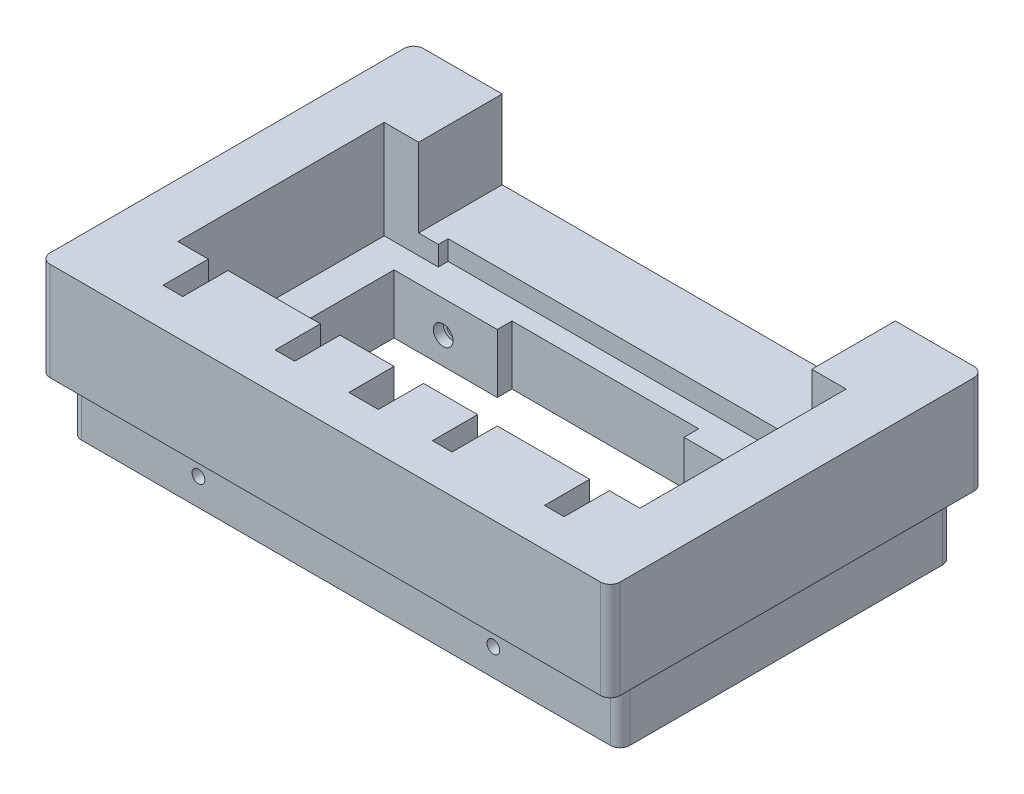
from build123d import *

# Parameters (mm, degrees)
SKETCH1_W               = 279
SKETCH1_H               = 169
BOSS_EXTRUDE1_DEPTH     = 30
SKETCH2_W               = 290
SKETCH2_H               = 190
BOSS_EXTRUDE2_DEPTH     = 50
FILLET1_R               = 5
FILLET2_R               = 5
SKETCH3_W               = 235
SKETCH3_H               = 105
CUT_EXTRUDE1_DEPTH      = 50
SKETCH4_W               = 200
SKETCH4_H               = 80
CUT_EXTRUDE2_DEPTH      = 50
SKETCH5_W               = 180
SKETCH5_H               = 5
CUT_EXTRUDE3_DEPTH      = 50
SKETCH6_W               = 95
SKETCH6_H               = 95
CUT_EXTRUDE4_DEPTH      = 50
SKETCH7_W               = 15
SKETCH7_H               = 23
SKETCH7_W_2             = 10
CUT_EXTRUDE5_DEPTH      = 50
SKETCH8_R               = 3.25
CUT_EXTRUDE6_DEPTH      = 180.5
SKETCH9_R               = 5
CUT_EXTRUDE7_DEPTH      = 45
CUT_EXTRUDE7_DEPTH_BACK = 45
SKETCH11_W              = 200
SKETCH11_H              = 40
CUT_EXTRUDE9_DEPTH      = 50


with BuildPart() as part:
    # Sketch1 → Boss-Extrude1 (new body)
    with BuildSketch(Plane(origin=(0, 0, 0), x_dir=(1, 0, 0), z_dir=(0, 1, 0))):
        Rectangle(SKETCH1_W, SKETCH1_H)
    extrude(amount=-BOSS_EXTRUDE1_DEPTH)

    # Sketch2 → Boss-Extrude2 (add)
    with BuildSketch(Plane(origin=(0, 0, 0), x_dir=(1, 0, 0), z_dir=(0, 1, 0))):
        Rectangle(SKETCH2_W, SKETCH2_H)
    extrude(amount=BOSS_EXTRUDE2_DEPTH)

    # Fillet1
    fillet1_edges = [part.edges().sort_by_distance(p)[0] for p in [
        (139.5, -15, 84.5),
        (-139.5, -15, 84.5),
        (-139.5, -15, -84.5),
        (139.5, -15, -84.5),
    ]]
    fillet(fillet1_edges, radius=FILLET1_R)

    # Fillet2
    fillet2_edges = [part.edges().sort_by_distance(p)[0] for p in [
        (145, 25, 95),
        (145, 25, -95),
        (-145, 25, -95),
        (-145, 25, 95),
    ]]
    fillet(fillet2_edges, radius=FILLET2_R)

    # Sketch3 → Cut-Extrude1 (cut)
    with BuildSketch(Plane(origin=(0, 50, 0), x_dir=(1, 0, 0), z_dir=(0, 1, 0))):
        Rectangle(SKETCH3_W, SKETCH3_H)
    extrude(amount=-CUT_EXTRUDE1_DEPTH, mode=Mode.SUBTRACT)

    # Sketch4 → Cut-Extrude2 (cut)
    with BuildSketch(Plane(origin=(0, 0, 0), x_dir=(1, 0, 0), z_dir=(0, 1, 0))):
        Rectangle(SKETCH4_W, SKETCH4_H)
    extrude(amount=-CUT_EXTRUDE2_DEPTH, mode=Mode.SUBTRACT)

    # Sketch5 → Cut-Extrude3 (cut)
    with BuildSketch(Plane(origin=(0, 50, 0), x_dir=(1, 0, 0), z_dir=(0, 1, 0))):
        with Locations((0, 55)):
            Rectangle(SKETCH5_W, SKETCH5_H)
    extrude(amount=-CUT_EXTRUDE3_DEPTH, mode=Mode.SUBTRACT)

    # Sketch6 → Cut-Extrude4 (cut)
    with BuildSketch(Plane(origin=(0, 0, 0), x_dir=(1, 0, 0), z_dir=(0, 1, 0))):
        Rectangle(SKETCH6_W, SKETCH6_H)
    extrude(amount=-CUT_EXTRUDE4_DEPTH, mode=Mode.SUBTRACT)

    # Sketch7 → Cut-Extrude5 (cut)
    with BuildSketch(Plane(origin=(0, 50, 0), x_dir=(1, 0, 0), z_dir=(0, 1, 0))):
        with Locations((0, -64)):
            Rectangle(SKETCH7_W, SKETCH7_H)
        with Locations((40, -64)):
            Rectangle(SKETCH7_W_2, SKETCH7_H)
        with Locations((-40, -64)):
            Rectangle(SKETCH7_W_2, SKETCH7_H)
        with Locations((97, -64)):
            Rectangle(SKETCH7_W_2, SKETCH7_H)
        with Locations((-97, -64)):
            Rectangle(SKETCH7_W_2, SKETCH7_H)
    extrude(amount=-CUT_EXTRUDE5_DEPTH, mode=Mode.SUBTRACT)

    # Sketch8 → Cut-Extrude6 (cut, through all)
    with BuildSketch(Plane(origin=(0, 0, -84.5), x_dir=(-1, 0, 0), z_dir=(0, 0, -1))):
        with Locations((75, -16.25)):
            Circle(SKETCH8_R)
        with Locations((-75, -16.25)):
            Circle(SKETCH8_R)
    extrude(amount=-CUT_EXTRUDE6_DEPTH, mode=Mode.SUBTRACT)

    # Sketch9 → Cut-Extrude7 (cut, two sides)
    with BuildSketch(Plane.XY) as cut_extrude7_sk:
        with Locations((-75, -16.25)):
            Circle(SKETCH9_R)
        with Locations((75, -16.25)):
            Circle(SKETCH9_R)
    extrude(amount=CUT_EXTRUDE7_DEPTH, mode=Mode.SUBTRACT)
    extrude(cut_extrude7_sk.sketch, amount=-CUT_EXTRUDE7_DEPTH_BACK, mode=Mode.SUBTRACT)

    # Sketch11 → Cut-Extrude9 (cut)
    with BuildSketch(Plane(origin=(0, 0, -95), x_dir=(-1, 0, 0), z_dir=(0, 0, -1))):
        with Locations((0, 30)):
            Rectangle(SKETCH11_W, SKETCH11_H)
    extrude(amount=-CUT_EXTRUDE9_DEPTH, mode=Mode.SUBTRACT)


solid = part.part
